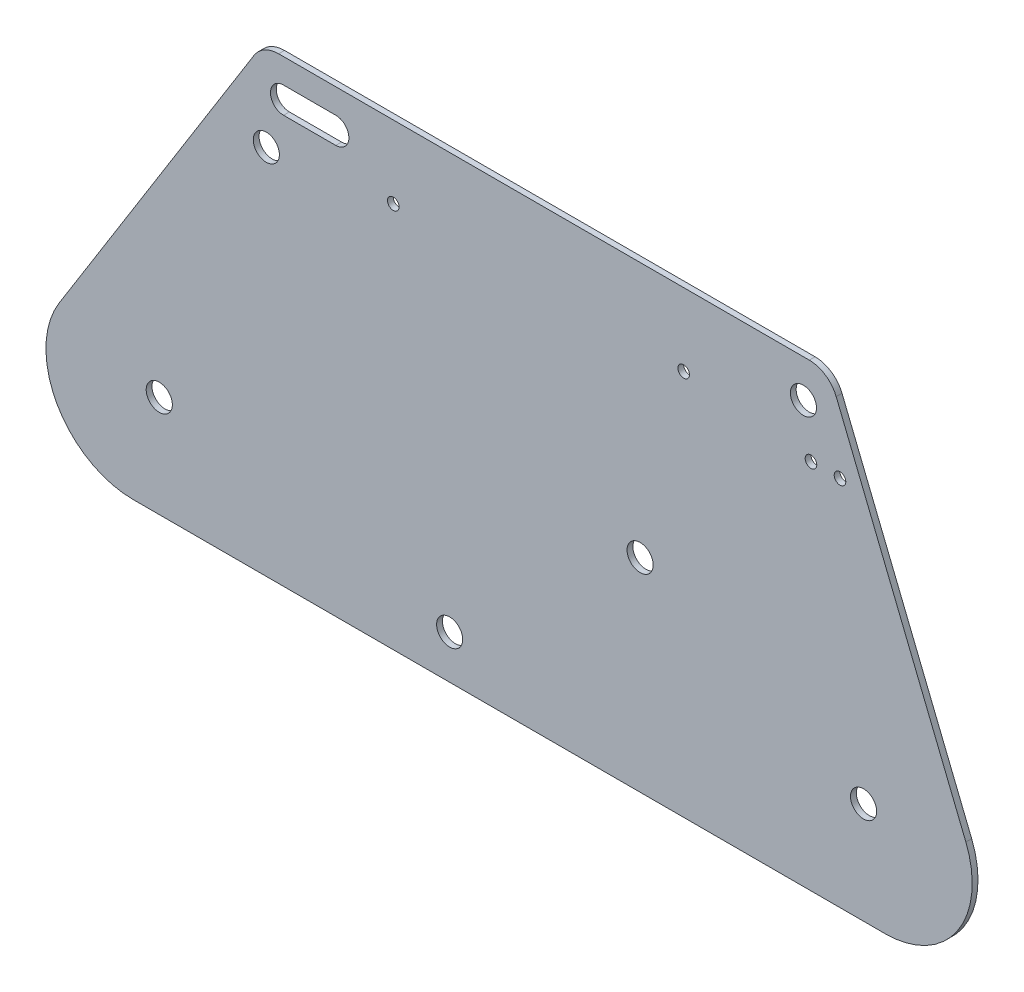
from build123d import *

# Parameters (mm, degrees)
SKETCH1_R           = 4.5
SKETCH1_R_2         = 2
BOSS_EXTRUDE1_DEPTH = 2
FILLET1_R           = 30
FILLET2_R           = 10


with BuildPart() as part:
    # Sketch1 → Boss-Extrude1 (new body)
    with BuildSketch(Plane.XY):
        Polygon((0, 0), (98.729357602, 158), (293.729357602, 158), (357.565501284, 0), align=None)
        with Locations((284.960746883, 145)):
            Circle(SKETCH1_R, mode=Mode.SUBTRACT)
        with Locations((305.675867386, 35)):
            Circle(SKETCH1_R, mode=Mode.SUBTRACT)
        with Locations((63.141671434, 35)):
            Circle(SKETCH1_R, mode=Mode.SUBTRACT)
        with Locations((163.141671434, 15)):
            Circle(SKETCH1_R, mode=Mode.SUBTRACT)
        with Locations((228.729357602, 70)):
            Circle(SKETCH1_R, mode=Mode.SUBTRACT)
        with Locations((100, 128)):
            Circle(SKETCH1_R, mode=Mode.SUBTRACT)
        with Locations((243.729357602, 133)):
            Circle(SKETCH1_R_2, mode=Mode.SUBTRACT)
        with Locations((143.729357602, 133)):
            Circle(SKETCH1_R_2, mode=Mode.SUBTRACT)
        with Locations((297.565501284, 128)):
            Circle(SKETCH1_R_2, mode=Mode.SUBTRACT)
        with Locations((287.565501284, 128)):
            Circle(SKETCH1_R_2, mode=Mode.SUBTRACT)
        with BuildLine():
            Line((105.935375271, 149.5), (123.935375271, 149.5))
            ThreePointArc((123.935375271, 149.5), (128.435375271, 145), (123.935375271, 140.5))
            Line((123.935375271, 140.5), (105.935375271, 140.5))
            ThreePointArc((105.935375271, 140.5), (101.435375271, 145), (105.935375271, 149.5))
        make_face(mode=Mode.SUBTRACT)
    extrude(amount=BOSS_EXTRUDE1_DEPTH)

    # Fillet1
    fillet1_edges = [part.edges().sort_by_distance(p)[0] for p in [
        (0, 0, 1),
        (357.565501284, 0, 1),
    ]]
    fillet(fillet1_edges, radius=FILLET1_R)

    # Fillet2
    fillet2_edges = [part.edges().sort_by_distance(p)[0] for p in [
        (98.729357602, 158, 1),
        (293.729357602, 158, 1),
    ]]
    fillet(fillet2_edges, radius=FILLET2_R)


solid = part.part
